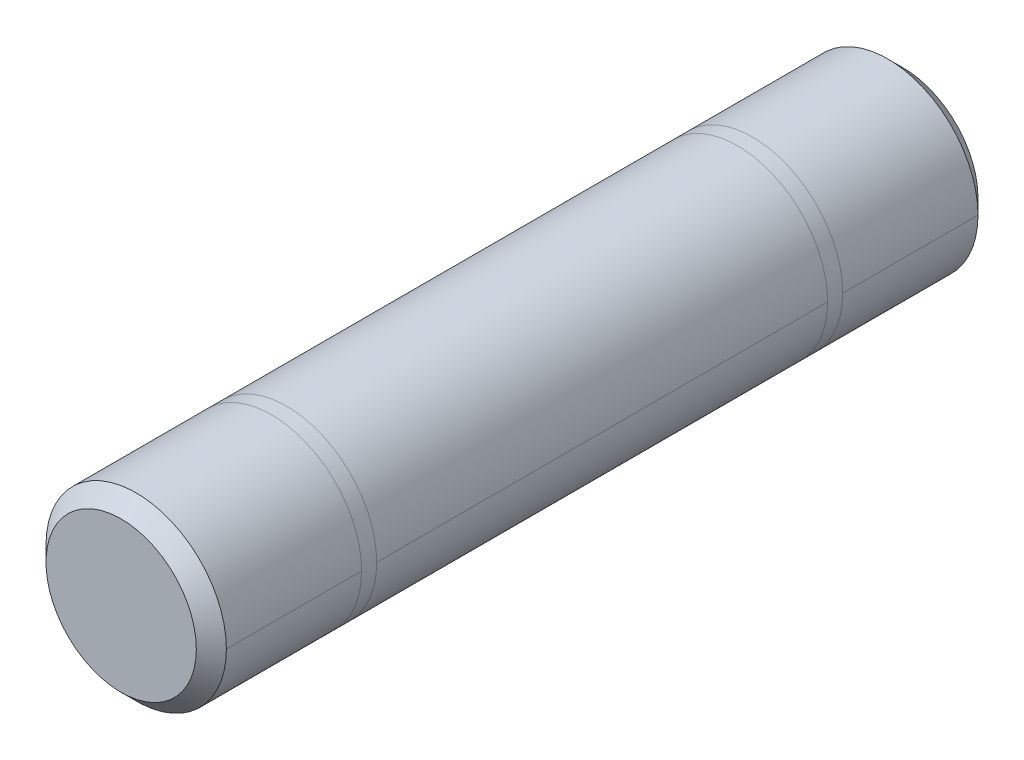
from build123d import *

# Parameters (mm, degrees)
ESQUISSE1_R        = 3
BOSS_EXTRU_1_DEPTH = 26
CHANFREIN1_SIZE    = 0.5


with BuildPart() as part:
    # Esquisse1 → Boss.-Extru.1 (new body)
    with BuildSketch(Plane.XY):
        Circle(ESQUISSE1_R)
    extrude(amount=BOSS_EXTRU_1_DEPTH)

    # Chanfrein1
    chanfrein1_edges = [part.edges().sort_by_distance(p)[0] for p in [
        (-3, 0, 0),
        (-3, 0, 26),
    ]]
    chamfer(chanfrein1_edges, length=CHANFREIN1_SIZE)


solid = part.part
